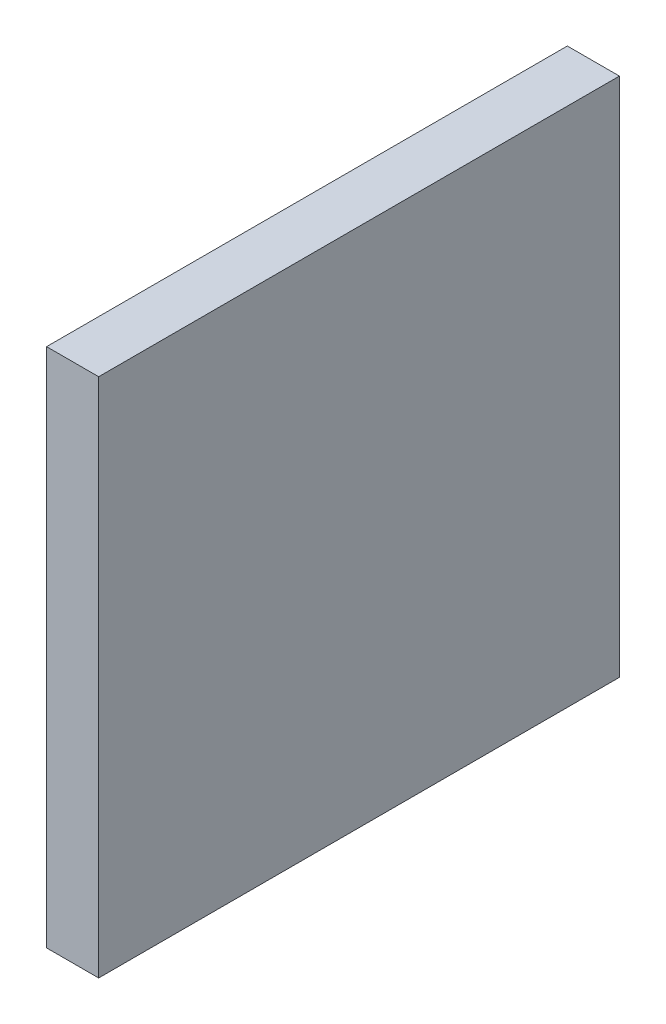
from build123d import *

# Parameters (mm, degrees)
SKETCH2_W           = 1000
SKETCH2_H           = 1000
BOSS_EXTRUDE2_DEPTH = 100
SKETCH4_W           = 145.74
SKETCH4_H           = 135.74
BOSS_EXTRUDE4_DEPTH = 8
FILLET1_R           = 10
SKETCH11_W          = 99.481944883
SKETCH11_H          = 99.481944883
BOSS_EXTRUDE6_DEPTH = 10
CUT_EXTRUDE2_DEPTH  = 199
FILLET5_R           = 5
SKETCH13_W          = 145.74
SKETCH13_H          = 10.277158346
CUT_EXTRUDE3_DEPTH  = 8
FILLET6_R           = 10


with BuildPart() as part:
    # Sketch2 → Boss-Extrude2 (new body)
    with BuildSketch(Plane(origin=(0, 0, 0), x_dir=(0, 0, -1), z_dir=(1, 0, 0))):
        with Locations((500, -500)):
            Rectangle(SKETCH2_W, SKETCH2_H)
    extrude(amount=BOSS_EXTRUDE2_DEPTH)

    # Sketch4 → Boss-Extrude4 (add)
    with BuildSketch(Plane.ZY):
        with Locations((-564.181498588, -429.969817094)):
            Rectangle(SKETCH4_W, SKETCH4_H)
    extrude(amount=BOSS_EXTRUDE4_DEPTH)

    # Fillet1
    fillet1_edges = [part.edges().sort_by_distance(p)[0] for p in [
        (-4, -362.099817094, -491.311498588),
        (-4, -362.099817094, -637.051498588),
        (-4, -497.839817094, -637.051498588),
        (-4, -497.839817094, -491.311498588),
    ]]
    fillet(fillet1_edges, radius=FILLET1_R)

    # Sketch11 → Boss-Extrude6 (add)
    with BuildSketch(Plane.ZY.offset(8)):
        with Locations((-562.051498588, -437.099817095)):
            Rectangle(SKETCH11_W, SKETCH11_H)
    extrude(amount=BOSS_EXTRUDE6_DEPTH)

    # Sketch12 → Cut-Extrude2 (cut)
    with BuildSketch(Plane(origin=(0, -486.840789536, 0), x_dir=(-1, 0, 0), z_dir=(0, -1, 0))):
        Polygon((8, 611.79247103), (18, 512.310526147), (18, 611.79247103), align=None)
    extrude(amount=-CUT_EXTRUDE2_DEPTH, mode=Mode.SUBTRACT)

    # Fillet5
    fillet5_edges = [part.edges().sort_by_distance(p)[0] for p in [
        (-13, -387.358844653, -512.310526147),
        (-13, -486.840789536, -512.310526147),
    ]]
    fillet(fillet5_edges, radius=FILLET5_R)

    # Sketch13 → Cut-Extrude3 (cut)
    with BuildSketch(Plane.ZY.offset(8)):
        with Locations((-564.181498588, -366.961237921)):
            Rectangle(SKETCH13_W, SKETCH13_H)
    extrude(amount=-CUT_EXTRUDE3_DEPTH, mode=Mode.SUBTRACT)

    # Fillet6
    fillet6_edges = [part.edges().sort_by_distance(p)[0] for p in [
        (-4, -372.099817094, -491.311498588),
        (-4, -372.099817094, -637.051498588),
    ]]
    fillet(fillet6_edges, radius=FILLET6_R)


solid = part.part
